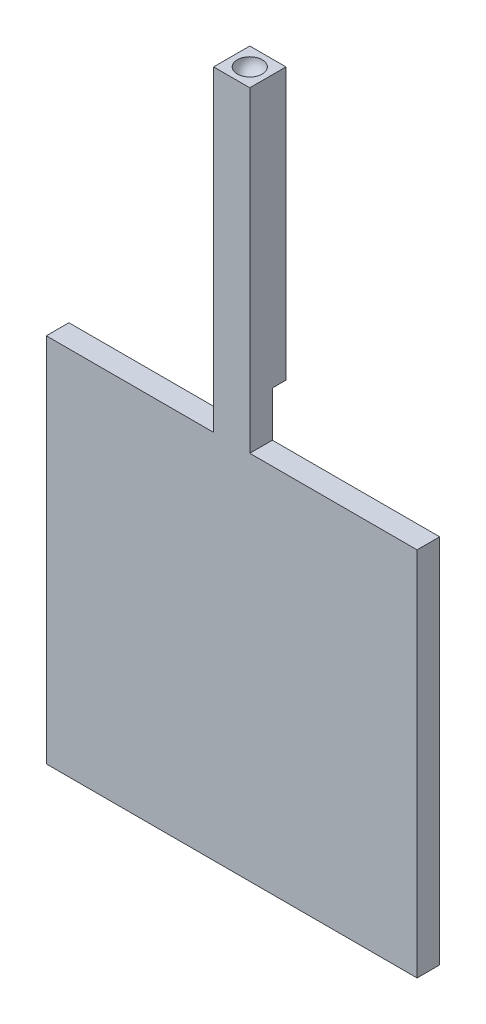
from build123d import *

# Parameters (mm, degrees)
SKETCH1_W           = 82
SKETCH1_H           = 82
BOSS_EXTRUDE1_DEPTH = 5
SKETCH2_W           = 8
SKETCH2_H           = 5
BOSS_EXTRUDE2_DEPTH = 10
SKETCH4_W           = 8
SKETCH4_H           = 8
BOSS_EXTRUDE4_DEPTH = 60
CUT_REVOLVE1_ANGLE  = 180
SKETCH6_W           = 7
SKETCH6_H           = 25
REVOLVE1_ANGLE      = 180


with BuildPart() as part:
    # Sketch1 → Boss-Extrude1 (new body)
    with BuildSketch(Plane.XY):
        with Locations((41, 41)):
            Rectangle(SKETCH1_W, SKETCH1_H)
    extrude(amount=BOSS_EXTRUDE1_DEPTH)

    # Sketch2 → Boss-Extrude2 (add)
    with BuildSketch(Plane(origin=(0, 82, 0), x_dir=(1, 0, 0), z_dir=(0, 1, 0))):
        with Locations((41, -2.5)):
            Rectangle(SKETCH2_W, SKETCH2_H)
    extrude(amount=BOSS_EXTRUDE2_DEPTH)

    # Sketch4 → Boss-Extrude4 (add)
    with BuildSketch(Plane(origin=(0, 92, 0), x_dir=(1, 0, 0), z_dir=(0, 1, 0))):
        with Locations((41, -1)):
            Rectangle(SKETCH4_W, SKETCH4_H)
    extrude(amount=BOSS_EXTRUDE4_DEPTH)

    # Sketch5 → Cut-Revolve1 (revolve, cut)
    with BuildSketch(Plane(origin=(0, 152, 0), x_dir=(1, 0, 0), z_dir=(0, 1, 0))):
        with BuildLine():
            Line((38.25, -1), (43.75, -1))
            ThreePointArc((43.75, -1), (41, -3.75), (38.25, -1))
        make_face()
    revolve(axis=Axis((38.25, 152, 1), (1, 0, 0)), revolution_arc=CUT_REVOLVE1_ANGLE, mode=Mode.SUBTRACT)

    # Sketch6 → Revolve1 (revolve)
    with BuildSketch(Plane(origin=(0, 0, 0), x_dir=(-1, 0, 0), z_dir=(0, 0, -1))):
        with Locations((-41, 27.5)):
            Rectangle(SKETCH6_W, SKETCH6_H)
    revolve(axis=Axis((37.5, 40, 0), (1, 0, 0)), revolution_arc=REVOLVE1_ANGLE)


solid = part.part
